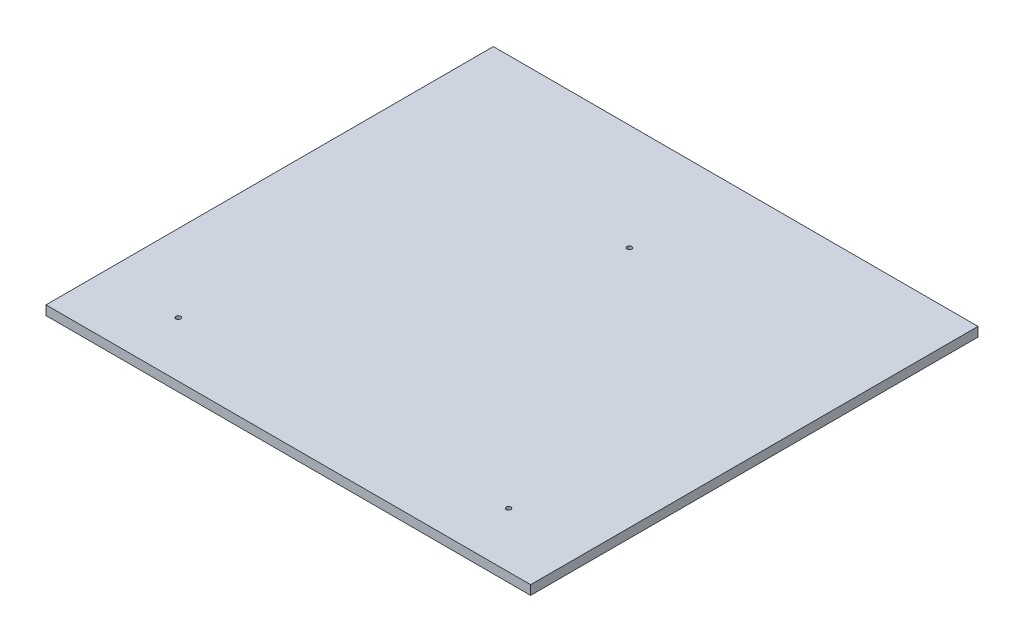
from build123d import *

# Parameters (mm, degrees)
SKETCH1_W           = 660.4
SKETCH1_H           = 609.6
BOSS_EXTRUDE1_DEPTH = 12.7
SKETCH5_R           = 3.175
CUT_EXTRUDE2_DEPTH  = 13.7


with BuildPart() as part:
    # Sketch1 → Boss-Extrude1 (new body)
    with BuildSketch(Plane(origin=(0, 0, 0), x_dir=(1, 0, 0), z_dir=(0, 1, 0))):
        with Locations((330.2, 304.8)):
            Rectangle(SKETCH1_W, SKETCH1_H)
    extrude(amount=BOSS_EXTRUDE1_DEPTH)

    # Sketch5 → Cut-Extrude2 (cut, through all)
    with BuildSketch(Plane(origin=(0, 12.7, 0), x_dir=(1, 0, 0), z_dir=(0, 1, 0))):
        with Locations((105.2, 75.116646637)):
            Circle(SKETCH5_R)
        with Locations((555.2, 75.116646637)):
            Circle(SKETCH5_R)
        with Locations((330.2, 464.82807834)):
            Circle(SKETCH5_R)
    extrude(amount=-CUT_EXTRUDE2_DEPTH, mode=Mode.SUBTRACT)


solid = part.part
